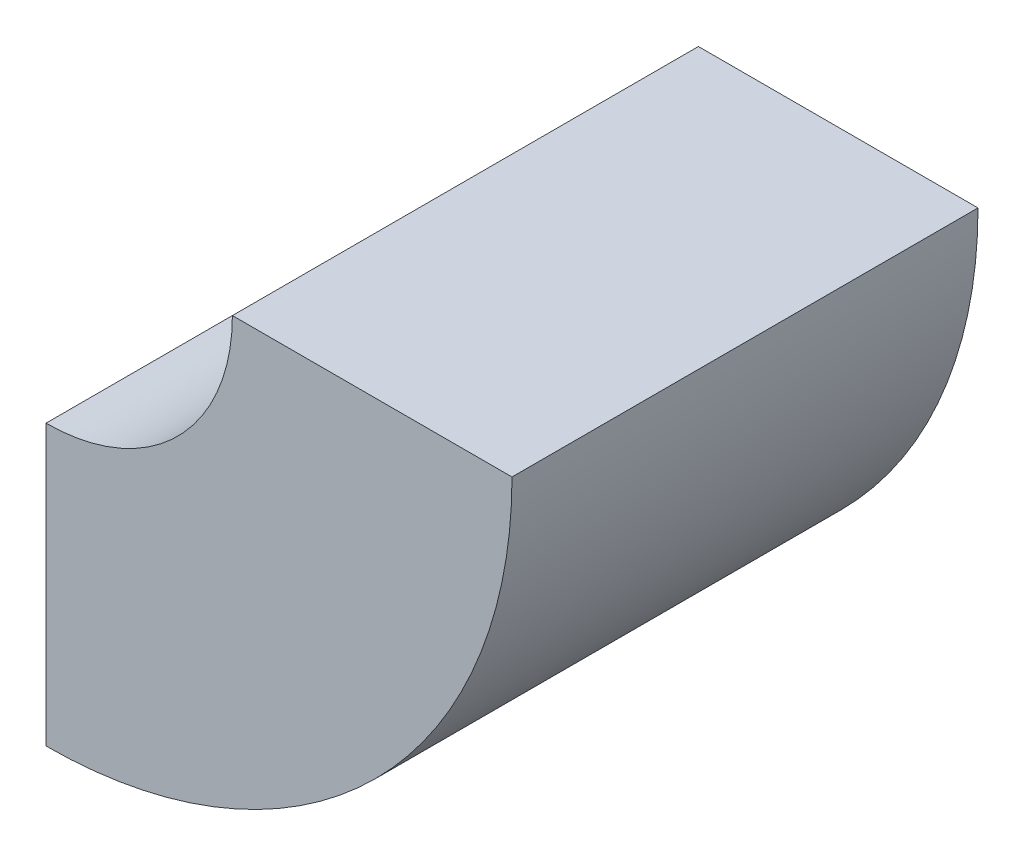
from build123d import *

# Parameters (mm, degrees)
BOSS_EXTRUDE1_DEPTH = 25


with BuildPart() as part:
    # Sketch1 → Boss-Extrude1 (new body)
    with BuildSketch(Plane.XY):
        with BuildLine():
            Line((-15, 0), (0, 0))
            ThreePointArc((0, 0), (-7.32233047, -17.67766953), (-25, -25))
            Line((-25, -25), (-25, -10))
            ThreePointArc((-25, -10), (-17.928932188, -7.071067812), (-15, 0))
        make_face()
    extrude(amount=BOSS_EXTRUDE1_DEPTH)


solid = part.part
